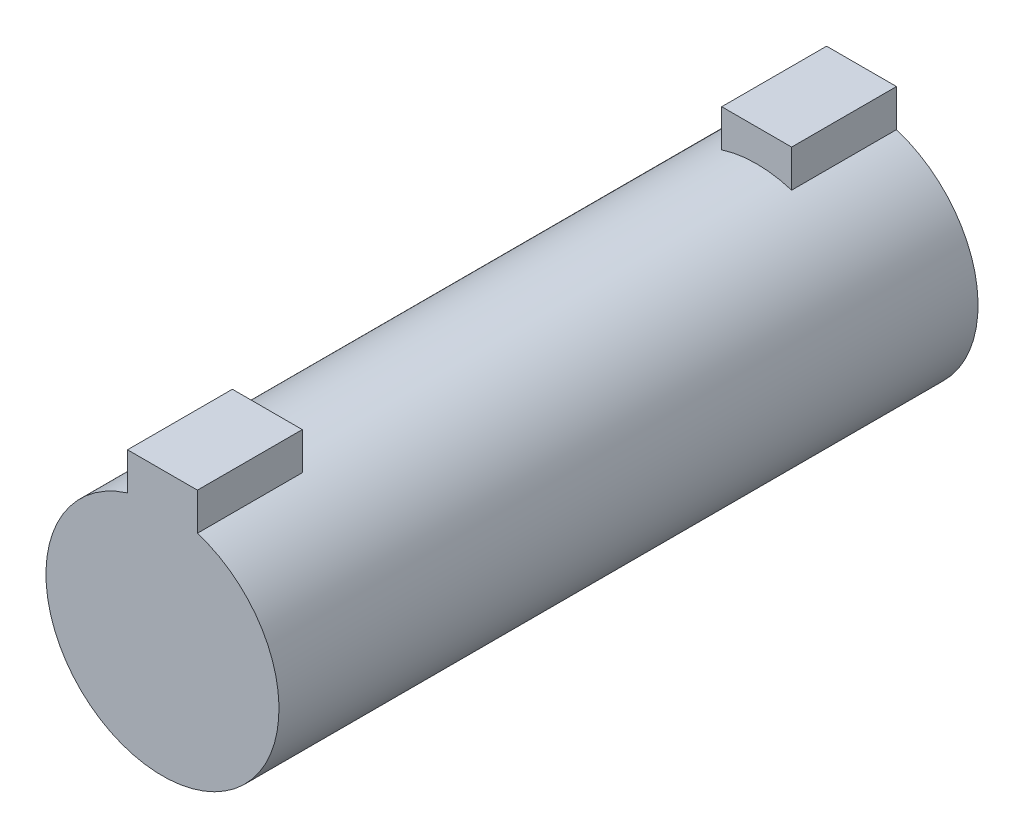
from build123d import *

# Parameters (mm, degrees)
SKETCH1_R           = 10
BOSS_EXTRUDE1_DEPTH = 30
SKETCH2_W           = 6
SKETCH2_H           = 3.26
BOSS_EXTRUDE2_DEPTH = 9


with BuildPart() as part:
    # Sketch1 → Boss-Extrude1 (new body, symmetric)
    with BuildSketch(Plane.XY):
        Circle(SKETCH1_R)
    extrude(amount=BOSS_EXTRUDE1_DEPTH, both=True)

    # Sketch2 → Boss-Extrude2 (add)
    with BuildSketch(Plane.XY.offset(30)):
        with Locations((0, 11.115019423)):
            Rectangle(SKETCH2_W, SKETCH2_H)
    boss_extrude2 = extrude(amount=-BOSS_EXTRUDE2_DEPTH)

    # Mirror1: Boss-Extrude2 across plane
    add(boss_extrude2.mirror(Plane.XY))


solid = part.part
